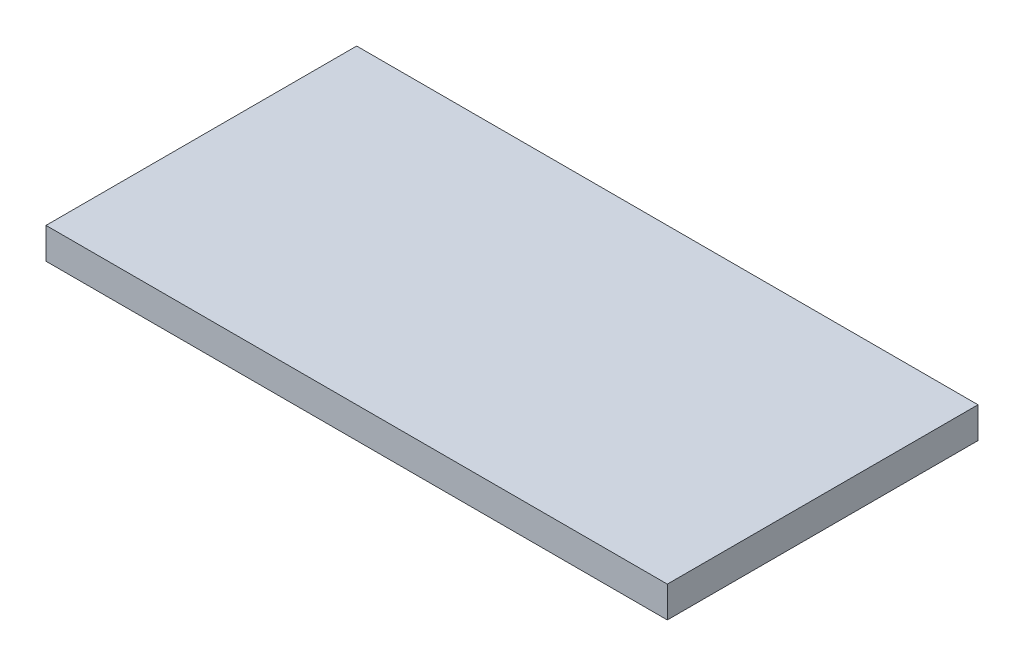
from build123d import *

# Parameters (mm, degrees)
SKETCH1_W           = 20
SKETCH1_H           = 10
BOSS_EXTRUDE1_DEPTH = 1


with BuildPart() as part:
    # Sketch1 → Boss-Extrude1 (new body)
    with BuildSketch(Plane(origin=(0, 0, 0), x_dir=(1, 0, 0), z_dir=(0, 1, 0))):
        Rectangle(SKETCH1_W, SKETCH1_H)
    extrude(amount=BOSS_EXTRUDE1_DEPTH)


solid = part.part
